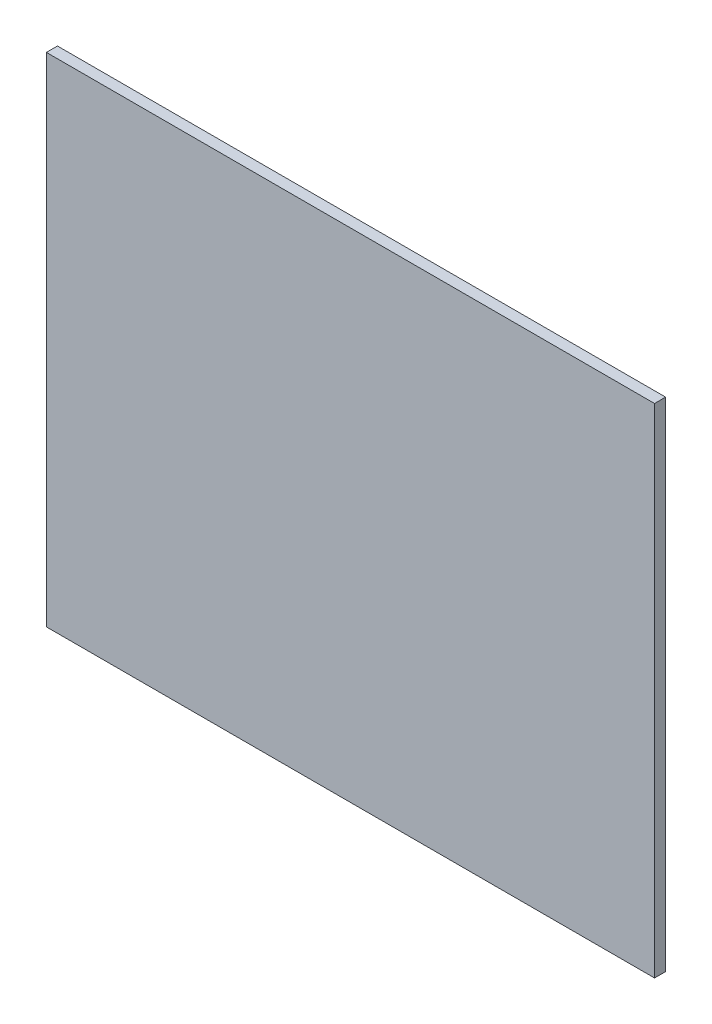
from build123d import *

# Parameters (mm, degrees)
SKETCH1_W           = 55
SKETCH1_H           = 45
BOSS_EXTRUDE1_DEPTH = 1


with BuildPart() as part:
    # Sketch1 → Boss-Extrude1 (new body)
    with BuildSketch(Plane.XY):
        Rectangle(SKETCH1_W, SKETCH1_H)
    extrude(amount=BOSS_EXTRUDE1_DEPTH)


solid = part.part
